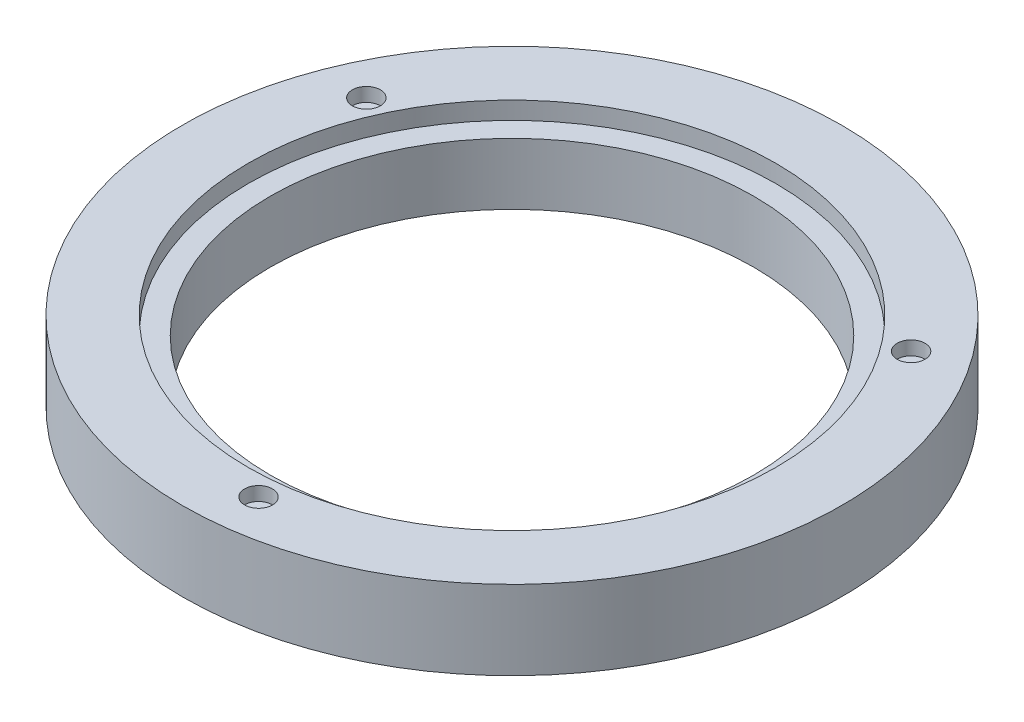
from build123d import *

# Parameters (mm, degrees)
ESQUISSE1_R             = 75
ESQUISSE1_R_2           = 55
BOSS_EXTRU_3_DEPTH      = 18
ESQUISSE6_R             = 60
ESQUISSE6_R_2           = 55
ENL_V_MAT_EXTRU_2_DEPTH = 4
ESQUISSE5_R             = 3.175
ENL_V_MAT_EXTRU_1_DEPTH = 3.15
ESQUISSE9_R             = 3.175
ENL_V_MAT_EXTRU_3_DEPTH = 3.15


with BuildPart() as part:
    # Esquisse1 → Boss.-Extru.3 (new body)
    with BuildSketch(Plane(origin=(0, 0, 0), x_dir=(1, 0, 0), z_dir=(0, 1, 0))):
        with Locations(Location((0, 0, 0), (0, 0, 270))):  # turned: the seam where the file's is
            Circle(ESQUISSE1_R)
        with Locations(Location((0, 0, 0), (0, 0, 270))):  # turned: the seam where the file's is
            Circle(ESQUISSE1_R_2, mode=Mode.SUBTRACT)
    extrude(amount=BOSS_EXTRU_3_DEPTH)

    # Esquisse6 → Enlèv. mat.-Extru.2 (cut)
    with BuildSketch(Plane(origin=(0, 18, 0), x_dir=(1, 0, 0), z_dir=(0, 1, 0))):
        with Locations(Location((0, 0, 0), (0, 0, 270))):  # turned: the seam where the file's is
            Circle(ESQUISSE6_R)
        with Locations(Location((0, 0, 0), (0, 0, 270))):  # turned: the seam where the file's is
            Circle(ESQUISSE6_R_2, mode=Mode.SUBTRACT)
    extrude(amount=-ENL_V_MAT_EXTRU_2_DEPTH, mode=Mode.SUBTRACT)

    # Esquisse5 → Enlèv. mat.-Extru.1 (cut)
    with BuildSketch(Plane(origin=(0, 18, 0), x_dir=(1, 0, 0), z_dir=(0, 1, 0))):
        with Locations(Location((-59.441823855, 26.299611723, 0), (0, 0, 270))):  # turned: the seam where the file's is
            Circle(ESQUISSE5_R)
        with Locations(Location((52.497043789, 38.328323645, 0), (0, 0, 270))):  # turned: the seam where the file's is
            Circle(ESQUISSE5_R)
        with Locations(Location((6.944780066, -64.627935367, 0), (0, 0, 270))):  # turned: the seam where the file's is
            Circle(ESQUISSE5_R)
    extrude(amount=-ENL_V_MAT_EXTRU_1_DEPTH, mode=Mode.SUBTRACT)

    # Esquisse9 → Enlèv. mat.-Extru.3 (cut)
    with BuildSketch(Plane.XZ):
        with Locations(Location((59.441823855, 26.299611723, 0), (0, 0, 270))):  # turned: the seam where the file's is
            Circle(ESQUISSE9_R)
        with Locations(Location((-6.944780066, -64.627935367, 0), (0, 0, 270))):  # turned: the seam where the file's is
            Circle(ESQUISSE9_R)
        with Locations(Location((-52.497043789, 38.328323645, 0), (0, 0, 270))):  # turned: the seam where the file's is
            Circle(ESQUISSE9_R)
    extrude(amount=-ENL_V_MAT_EXTRU_3_DEPTH, mode=Mode.SUBTRACT)


solid = part.part
